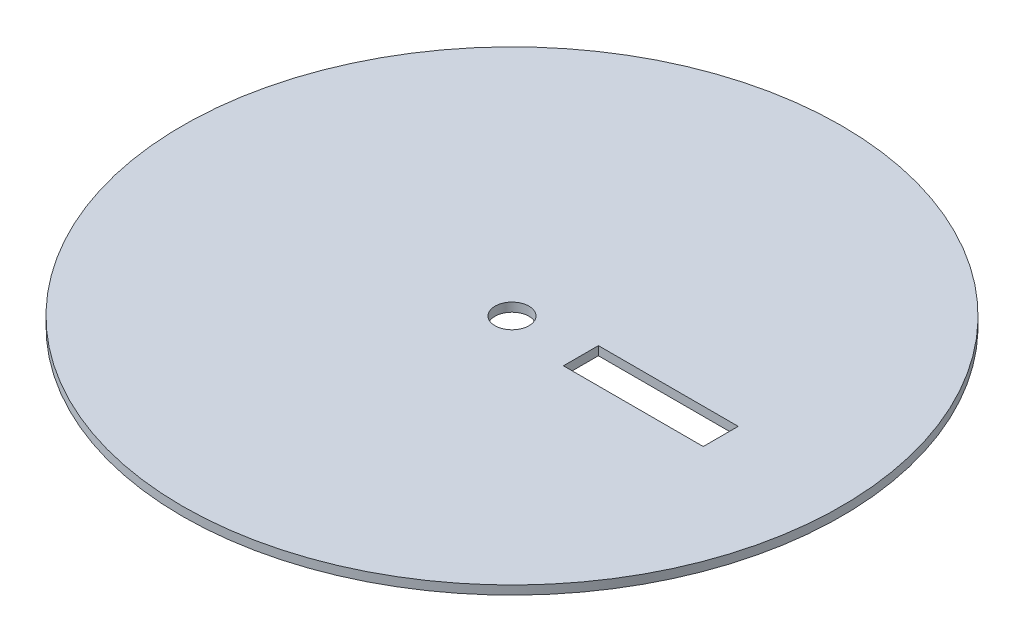
from build123d import *

# Parameters (mm, degrees)
SKETCH1_R           = 16.5
BOSS_EXTRUDE1_DEPTH = 0.44
SKETCH2_R           = 0.85
SKETCH2_W           = 7
SKETCH2_H           = 1.75
CUT_EXTRUDE1_DEPTH  = 0.44


with BuildPart() as part:
    # Sketch1 → Boss-Extrude1 (new body)
    with BuildSketch(Plane(origin=(0, 0, 0), x_dir=(1, 0, 0), z_dir=(0, 1, 0))):
        Circle(SKETCH1_R)
    extrude(amount=BOSS_EXTRUDE1_DEPTH)

    # Sketch2 → Cut-Extrude1 (cut)
    with BuildSketch(Plane(origin=(0, 0.44, 0), x_dir=(1, 0, 0), z_dir=(0, 1, 0))):
        Circle(SKETCH2_R)
        with Locations((6.95, 0)):
            Rectangle(SKETCH2_W, SKETCH2_H)
    extrude(amount=-CUT_EXTRUDE1_DEPTH, mode=Mode.SUBTRACT)


solid = part.part
